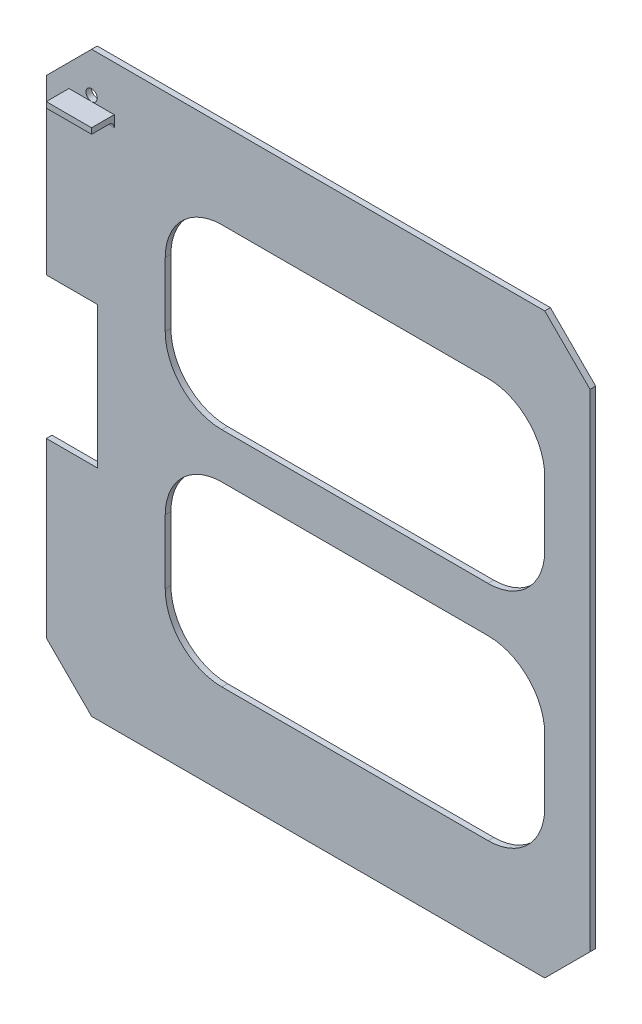
from build123d import *

# Parameters (mm, degrees)
BOSS_EXTRUDE2_DEPTH = 3.175
SKETCH4_W           = 28.575
SKETCH4_H           = 79.375
CUT_EXTRUDE2_DEPTH  = 3.175
CUT_EXTRUDE3_DEPTH  = 3.175
SKETCH9_R           = 3.175
CUT_EXTRUDE4_DEPTH  = 3.175
SKETCH11_W          = 25.4
SKETCH11_H          = 3.175
BOSS_EXTRUDE3_DEPTH = 12.7
FILLET2_R           = 3.175


with BuildPart() as part:
    # Sketch1 → Boss-Extrude2 (new body)
    with BuildSketch(Plane.XY):
        Polygon((0, 298.45), (25.4, 323.85), (279.4, 323.85), (304.8, 298.45), (304.8, 25.4), (279.4, 0), (25.4, 0), (0, 25.4), align=None)
    extrude(amount=BOSS_EXTRUDE2_DEPTH)

    # Sketch4 → Cut-Extrude2 (cut)
    with BuildSketch(Plane.XY.offset(3.175)):
        with Locations((14.2875, 161.925)):
            Rectangle(SKETCH4_W, SKETCH4_H)
    extrude(amount=-CUT_EXTRUDE2_DEPTH, mode=Mode.SUBTRACT)

    # Sketch5 → Cut-Extrude3 (cut)
    with BuildSketch(Plane.XY.offset(3.175)):
        with BuildLine():
            Line((98.425, 275.149783319), (247.65, 275.149783319))
            ThreePointArc((247.65, 275.149783319), (270.100640303, 265.850423621), (279.4, 243.399783319))
            Line((279.4, 243.399783319), (279.4, 207.424891659))
            ThreePointArc((279.4, 207.424891659), (270.100640303, 184.974251357), (247.65, 175.674891659))
            Line((247.65, 175.674891659), (98.425, 175.674891659))
            ThreePointArc((98.425, 175.674891659), (75.974359697, 184.974251357), (66.675, 207.424891659))
            Line((66.675, 207.424891659), (66.675, 243.399783319))
            ThreePointArc((66.675, 243.399783319), (75.974359697, 265.850423621), (98.425, 275.149783319))
        make_face()
        with BuildLine():
            Line((98.425, 150.274891659), (247.65, 150.274891659))
            ThreePointArc((247.65, 150.274891659), (270.100640303, 140.975531962), (279.4, 118.524891659))
            Line((279.4, 118.524891659), (279.4, 82.55))
            ThreePointArc((279.4, 82.55), (270.100640303, 60.099359697), (247.65, 50.8))
            Line((247.65, 50.8), (98.425, 50.8))
            ThreePointArc((98.425, 50.8), (75.974359697, 60.099359697), (66.675, 82.55))
            Line((66.675, 82.55), (66.675, 118.524891659))
            ThreePointArc((66.675, 118.524891659), (75.974359697, 140.975531962), (98.425, 150.274891659))
        make_face()
    extrude(amount=-CUT_EXTRUDE3_DEPTH, mode=Mode.SUBTRACT)

    # Sketch9 → Cut-Extrude4 (cut)
    with BuildSketch(Plane.XY.offset(3.175)):
        with Locations((25.4, 301.625)):
            Circle(SKETCH9_R)
    extrude(amount=-CUT_EXTRUDE4_DEPTH, mode=Mode.SUBTRACT)

    # Sketch11 → Boss-Extrude3 (add)
    with BuildSketch(Plane.XY.offset(3.175)):
        with Locations((25.4, 296.8625)):
            Rectangle(SKETCH11_W, SKETCH11_H)
    extrude(amount=BOSS_EXTRUDE3_DEPTH)

    # Fillet2
    fillet2_edges = [part.edges().sort_by_distance(p)[0] for p in [
        (25.4, 295.275, 3.175),
    ]]
    fillet(fillet2_edges, radius=FILLET2_R)


solid = part.part
